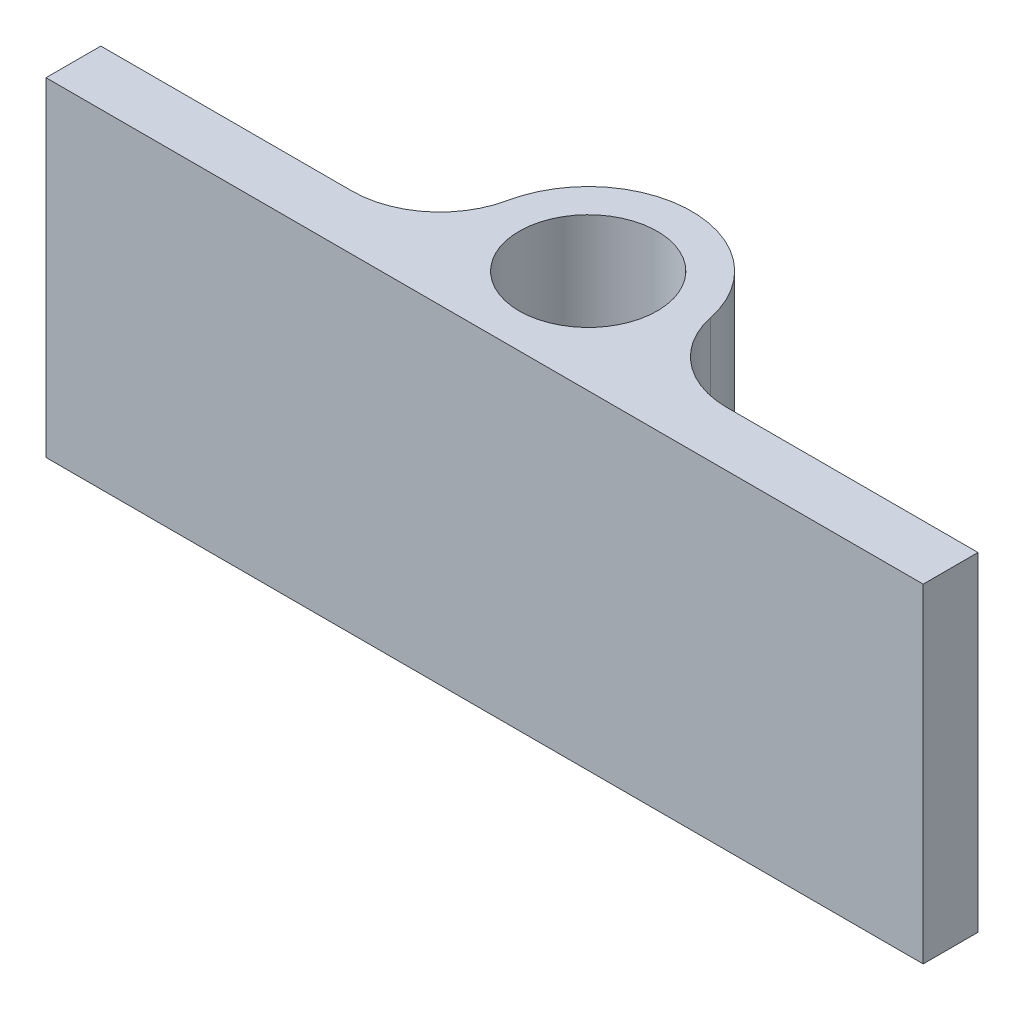
from build123d import *

# Parameters (mm, degrees)
SKETCH1_R           = 2
BOSS_EXTRUDE1_DEPTH = 9.525
FILLET1_R           = 2.54


with BuildPart() as part:
    # Sketch1 → Boss-Extrude1 (new body)
    with BuildSketch(Plane(origin=(0, 0, 0), x_dir=(1, 0, 0), z_dir=(0, 1, 0))):
        with BuildLine():
            Line((-12.7, -1.4125), (-12.7, -3))
            Line((-12.7, -3), (12.7, -3))
            Line((12.7, -3), (12.7, -1.4125))
            Line((12.7, -1.4125), (2.646666535, -1.4125))
            ThreePointArc((2.646666535, -1.4125), (0, 3), (-2.646666535, -1.4125))
            Line((-2.646666535, -1.4125), (-12.7, -1.4125))
        make_face()
        Circle(SKETCH1_R, mode=Mode.SUBTRACT)
    extrude(amount=BOSS_EXTRUDE1_DEPTH)

    # Fillet1
    fillet1_edges = [part.edges().sort_by_distance(p)[0] for p in [
        (-2.646666535, 4.7625, 1.4125),
        (2.646666535, 4.7625, 1.4125),
    ]]
    fillet(fillet1_edges, radius=FILLET1_R)


solid = part.part
